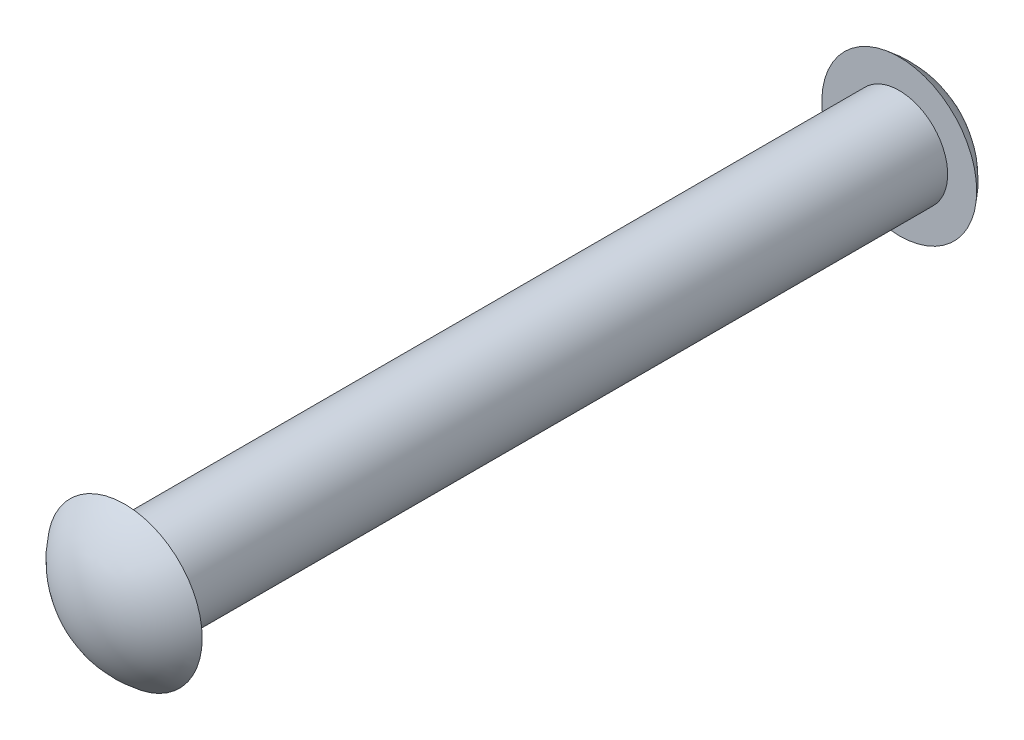
from build123d import *

# Parameters (mm, degrees)
SKETCH2_R           = 3.175
BOSS_EXTRUDE1_DEPTH = 50.8


with BuildPart() as part:
    # Sketch2 → Boss-Extrude1 (new body)
    with BuildSketch(Plane.XY):
        Circle(SKETCH2_R)
    extrude(amount=BOSS_EXTRUDE1_DEPTH)

    # Sketch6 → Revolve2 (revolve)
    with BuildSketch(Plane(origin=(0, 0, 0), x_dir=(0, 0, -1), z_dir=(1, 0, 0))):
        with BuildLine():
            Line((-50.8, 0), (-50.8, 5.08))
            ThreePointArc((-50.8, 5.08), (-52.669612663, 2.839806331), (-53.34, 0))
            Line((-53.34, 0), (-50.8, 0))
        make_face()
        with BuildLine():
            Line((0, 0), (2.54, 0))
            ThreePointArc((2.54, 0), (1.869612663, 2.839806331), (0, 5.08))
            Line((0, 5.08), (0, 0))
        make_face()
    revolve(axis=Axis((0, 0, 50.8), (0, 0, -1)))


solid = part.part
